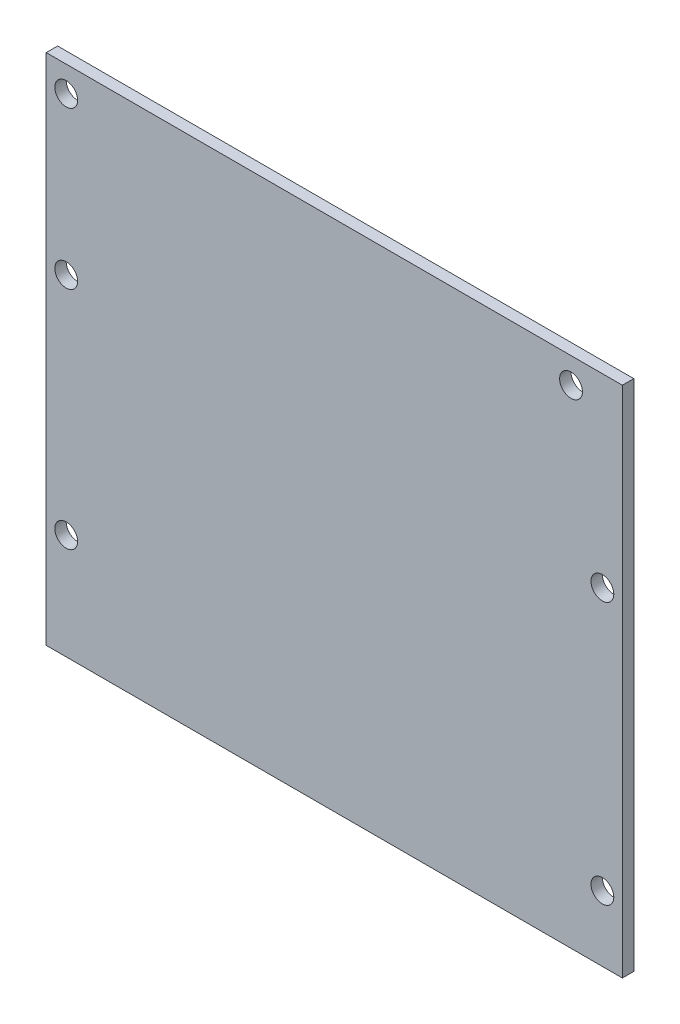
from build123d import *

# Parameters (mm, degrees)
ESQUISSE1_W       = 101
ESQUISSE1_H       = 90
MAIN_SKETCH_DEPTH = 2
HOLE_SKETCH_R     = 2
HOLES_DEPTH       = 3


with BuildPart() as part:
    # Esquisse1 → Main-Sketch (new body)
    with BuildSketch(Plane.XY):
        with Locations((50.5, 45)):
            Rectangle(ESQUISSE1_W, ESQUISSE1_H)
    extrude(amount=MAIN_SKETCH_DEPTH)

    # Hole Sketch → Holes (cut, through all)
    with BuildSketch(Plane.XY.offset(2)):
        with Locations((97.5, 11.5)):
            Circle(HOLE_SKETCH_R)
        with Locations((97.5, 57.5)):
            Circle(HOLE_SKETCH_R)
        with Locations((3.5, 18.5)):
            Circle(HOLE_SKETCH_R)
        with Locations((3.5, 58)):
            Circle(HOLE_SKETCH_R)
        with Locations((3.5, 85.5)):
            Circle(HOLE_SKETCH_R)
        with Locations((92, 85.5)):
            Circle(HOLE_SKETCH_R)
    extrude(amount=-HOLES_DEPTH, mode=Mode.SUBTRACT)


solid = part.part
